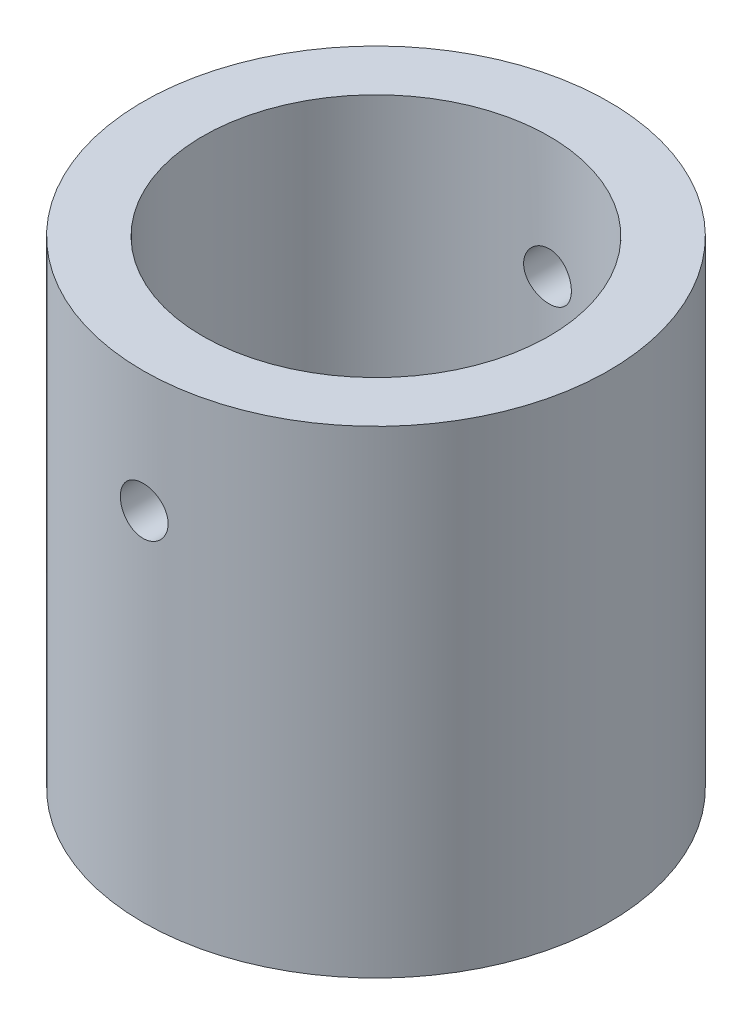
from build123d import *

# Parameters (mm, degrees)
SKETCH1_R           = 19.5
SKETCH1_R_2         = 14.5
BOSS_EXTRUDE1_DEPTH = 40
SKETCH2_R           = 2
CUT_EXTRUDE1_DEPTH  = 42


with BuildPart() as part:
    # Sketch1 → Boss-Extrude1 (new body)
    with BuildSketch(Plane(origin=(0, 0, 0), x_dir=(1, 0, 0), z_dir=(0, 1, 0))):
        Circle(SKETCH1_R)
        Circle(SKETCH1_R_2, mode=Mode.SUBTRACT)
    extrude(amount=BOSS_EXTRUDE1_DEPTH)

    # Sketch2 → Cut-Extrude1 (cut)
    with BuildSketch(Plane.XY.offset(19.5)):
        with Locations((0, 29.84)):
            Circle(SKETCH2_R)
    extrude(amount=-CUT_EXTRUDE1_DEPTH, mode=Mode.SUBTRACT)


solid = part.part
